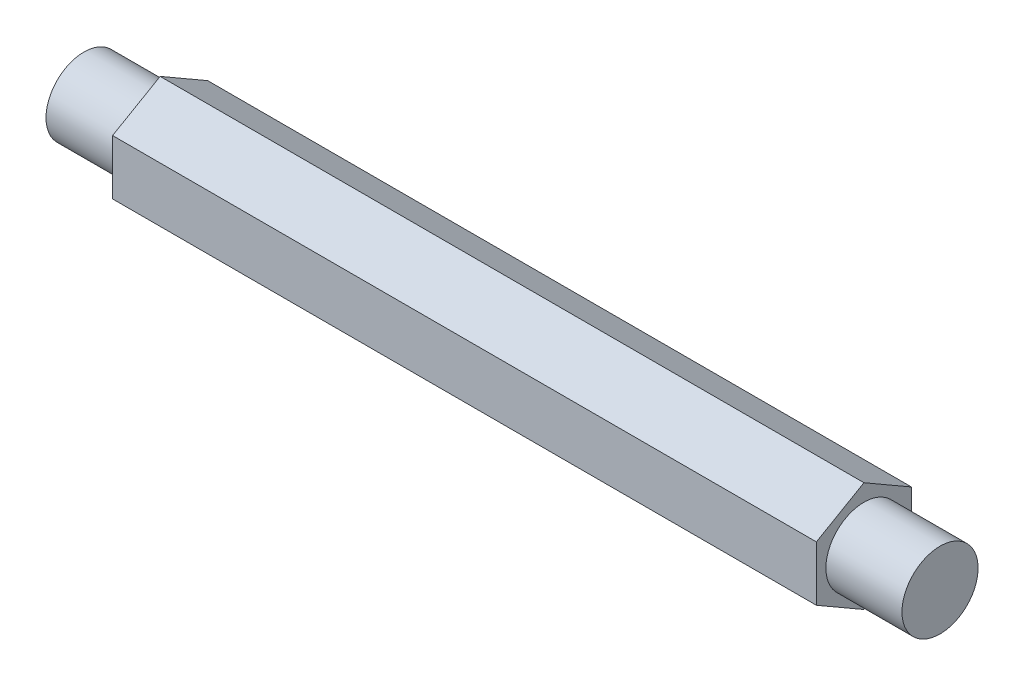
from build123d import *

# Parameters (mm, degrees)
BOSS_EXTRUDE1_DEPTH = 37


with BuildPart() as part:
    # Sketch1 → Revolve1 (revolve)
    with BuildSketch(Plane.XY):
        Polygon((0, 2), (-4, 2), (-4, 0), (41, 0), (41, 2), (37, 2), (37, 2.5), (0, 2.5), align=None)
    revolve(axis=Axis((-6.185185185, 0, 0), (1, 0, 0)))

    # Sketch2 → Boss-Extrude1 (add)
    with BuildSketch(Plane(origin=(0, 0, 0), x_dir=(0, 0, -1), z_dir=(1, 0, 0))):
        Polygon((0, 2.886751346), (-2.5, 1.443375673), (-2.5, -1.443375673), (0, -2.886751346), (2.5, -1.443375673), (2.5, 1.443375673), align=None)
    extrude(amount=BOSS_EXTRUDE1_DEPTH)


solid = part.part
